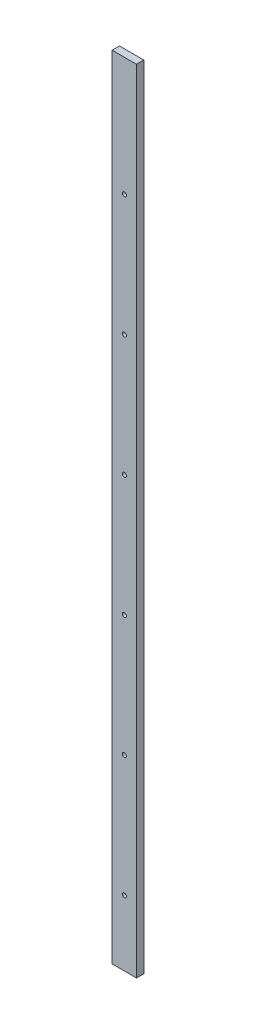
from build123d import *

# Parameters (mm, degrees)
SKETCH1_W           = 40
SKETCH1_H           = 12
BOSS_EXTRUDE1_DEPTH = 1303.36
SKETCH2_R           = 3.4
CUT_EXTRUDE1_DEPTH  = 13


with BuildPart() as part:
    # Sketch1 → Boss-Extrude1 (new body)
    with BuildSketch(Plane(origin=(0, 0, 0), x_dir=(1, 0, 0), z_dir=(0, 1, 0))):
        Rectangle(SKETCH1_W, SKETCH1_H)
    extrude(amount=-BOSS_EXTRUDE1_DEPTH)

    # Sketch2 → Cut-Extrude1 (cut, through all)
    with BuildSketch(Plane.XY.offset(6)):
        with Locations((0, -995.5)):
            Circle(SKETCH2_R)
        with Locations((0, -795.5)):
            Circle(SKETCH2_R)
        with Locations((0, -395.5)):
            Circle(SKETCH2_R)
        with Locations((0, -195.5)):
            Circle(SKETCH2_R)
        with Locations((0, 4.5)):
            Circle(SKETCH2_R)
        with Locations((0, -595.5)):
            Circle(SKETCH2_R)
        with Locations((0, -1195.5)):
            Circle(SKETCH2_R)
    extrude(amount=-CUT_EXTRUDE1_DEPTH, mode=Mode.SUBTRACT)


solid = part.part
